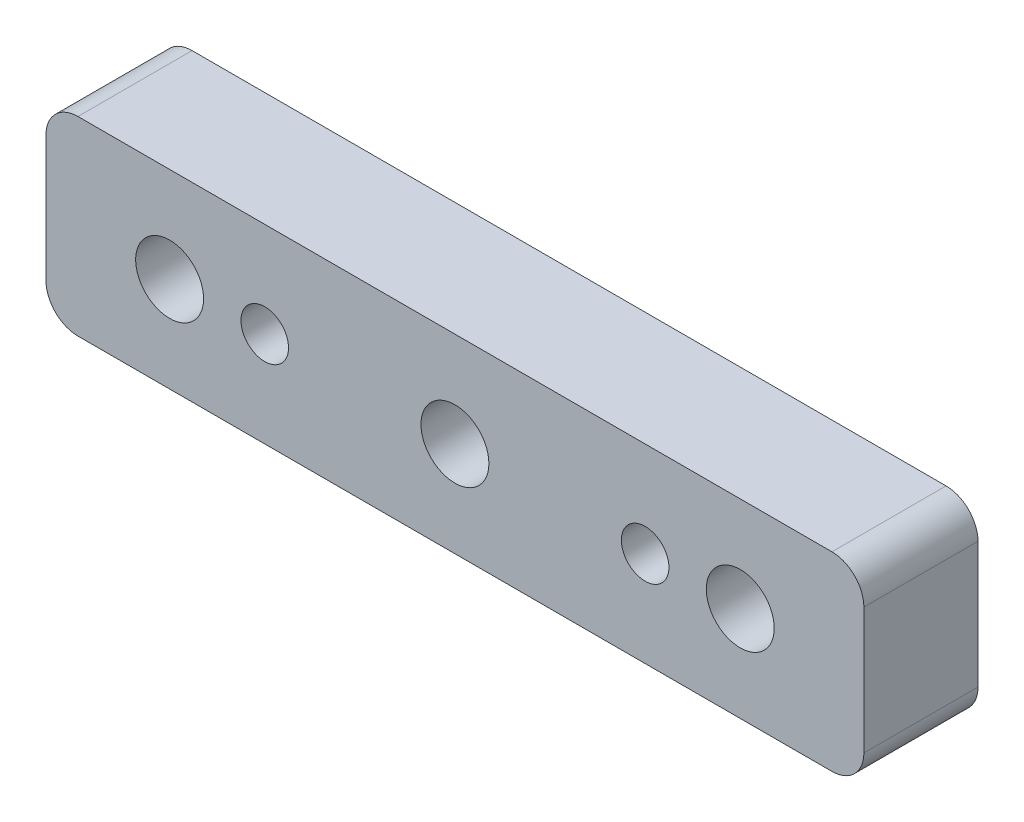
from build123d import *

# Parameters (mm, degrees)
SKETCH1_R           = 3.57
SKETCH1_R_2         = 2.5
BOSS_EXTRUDE1_DEPTH = 6


with BuildPart() as part:
    # Sketch1 → Boss-Extrude1 (new body, symmetric)
    with BuildSketch(Plane.XY):
        with BuildLine():
            Line((-39.64, -10), (39.64, -10))
            ThreePointArc((39.64, -10), (42.015878785, -9.015878785), (43, -6.64))
            Line((43, -6.64), (43, 6.64))
            ThreePointArc((43, 6.64), (42.015878785, 9.015878785), (39.64, 10))
            Line((39.64, 10), (-39.64, 10))
            ThreePointArc((-39.64, 10), (-42.015878785, 9.015878785), (-43, 6.64))
            Line((-43, 6.64), (-43, -6.64))
            ThreePointArc((-43, -6.64), (-42.015878785, -9.015878785), (-39.64, -10))
        make_face()
        with Locations((-30, 0)):
            Circle(SKETCH1_R, mode=Mode.SUBTRACT)
        Circle(SKETCH1_R, mode=Mode.SUBTRACT)
        with Locations((30, 0)):
            Circle(SKETCH1_R, mode=Mode.SUBTRACT)
        with Locations((-20, 0)):
            Circle(SKETCH1_R_2, mode=Mode.SUBTRACT)
        with Locations((20, 0)):
            Circle(SKETCH1_R_2, mode=Mode.SUBTRACT)
    extrude(amount=BOSS_EXTRUDE1_DEPTH, both=True)


solid = part.part
